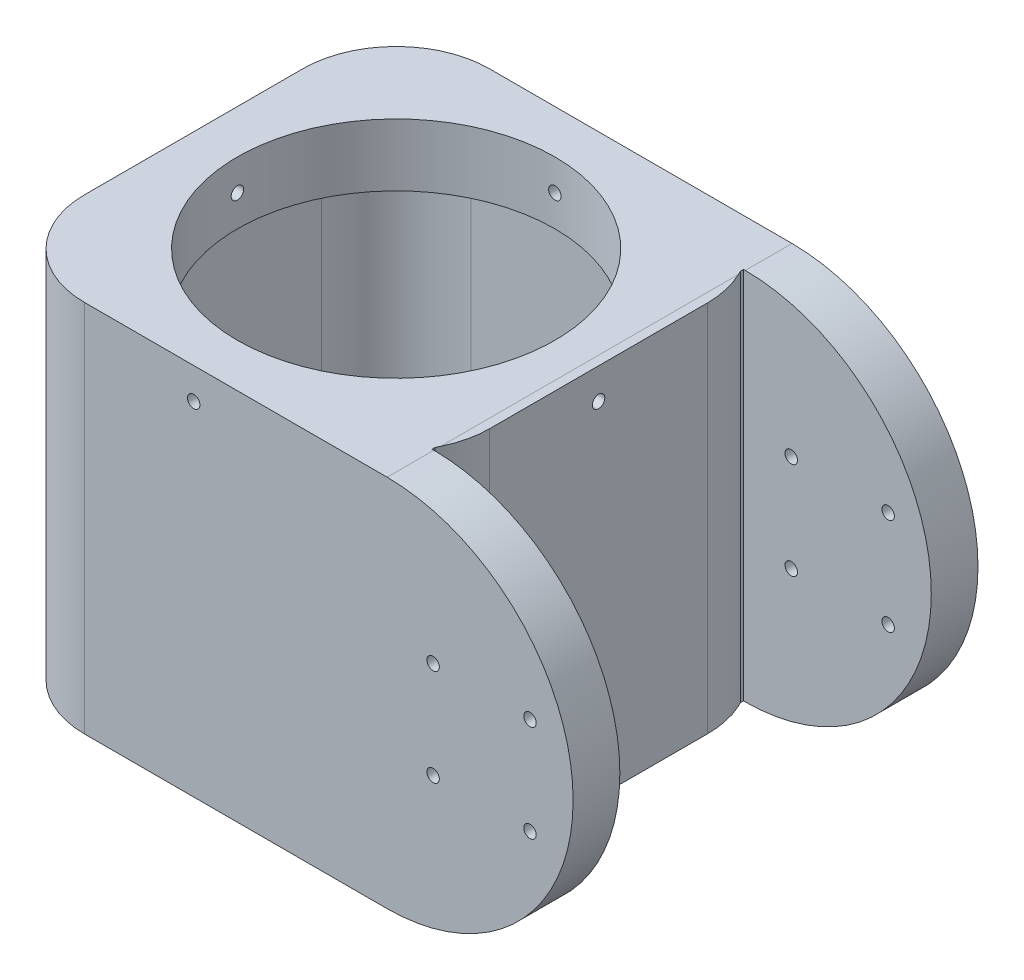
from build123d import *

# Parameters (mm, degrees)
BOSS_EXTRUDE1_DEPTH      = 40
SKETCH2_R                = 25.5
BOSS_EXTRUDE2_DEPTH      = 20
SKETCH3_R                = 4
CUT_EXTRUDE1_DEPTH       = 20
SKETCH5_R                = 1.5
CUT_EXTRUDE4_DEPTH       = 13.5
CUT_EXTRUDE5_DEPTH       = 3
BOSS_EXTRUDE3_DEPTH      = 60
CUT_EXTRUDE6_DEPTH       = 60
SKETCH9_R                = 1.5
CUT_EXTRUDE7_DEPTH       = 60
BOSS_EXTRUDE4_DEPTH      = 60
SKETCH12_R               = 1.5
CUT_EXTRUDE8_DEPTH       = 8
CUT_EXTRUDE9_DEPTH       = 0.5
CUT_EXTRUDE10_DEPTH      = 0.5
SKETCH15_R               = 4
SKETCH15_R_2             = 1.5
BOSS_EXTRUDE5_DEPTH      = 3
SKETCH16_R               = 1
CUT_EXTRUDE11_DEPTH      = 117
SKETCH19_R               = 1
BOSS_EXTRUDE7_DEPTH      = 43
SKETCH21_R               = 25.5
CUT_EXTRUDE12_DEPTH      = 33
CUT_EXTRUDE13_DEPTH      = 7
SKETCH24_R               = 1
CUT_EXTRUDE14_DEPTH      = 10
CUT_EXTRUDE14_DEPTH_BACK = 100
SKETCH25_R               = 1
CUT_EXTRUDE15_DEPTH      = 100
CUT_EXTRUDE15_DEPTH_BACK = 100
SKETCH29_R               = 1
BOSS_EXTRUDE9_DEPTH      = 10
SKETCH30_R               = 1.5
SKETCH30_R_2             = 1
BOSS_EXTRUDE10_DEPTH     = 7.5
SKETCH34_R               = 1.5
SKETCH34_R_2             = 1
BOSS_EXTRUDE12_DEPTH     = 7.5


with BuildPart() as part:
    # Sketch1 → Boss-Extrude1 (new body)
    with BuildSketch(Plane(origin=(0, 0, 0), x_dir=(1, 0, 0), z_dir=(0, 1, 0))):
        with BuildLine():
            Line((-17.090813971, 31.818023286), (17.909186029, 31.818023286))
            ThreePointArc((17.909186029, 31.818023286), (28.515787746, 27.424625004), (32.909186029, 16.818023286))
            Line((32.909186029, 16.818023286), (32.909186029, -18.181976714))
            ThreePointArc((32.909186029, -18.181976714), (28.515787746, -28.788578432), (17.909186029, -33.181976714))
            Line((17.909186029, -33.181976714), (-17.090813971, -33.181976714))
            ThreePointArc((-17.090813971, -33.181976714), (-27.697415689, -28.788578432), (-32.090813971, -18.181976714))
            Line((-32.090813971, -18.181976714), (-32.090813971, 16.818023286))
            ThreePointArc((-32.090813971, 16.818023286), (-27.697415689, 27.424625004), (-17.090813971, 31.818023286))
        make_face()
        with BuildLine():
            Line((-17.090813971, 28.818023286), (17.909186029, 28.818023286))
            ThreePointArc((17.909186029, 28.818023286), (26.394467403, 25.30330466), (29.909186029, 16.818023286))
            Line((29.909186029, 16.818023286), (29.909186029, -18.181976714))
            ThreePointArc((29.909186029, -18.181976714), (26.394467403, -26.667258088), (17.909186029, -30.181976714))
            Line((17.909186029, -30.181976714), (-17.090813971, -30.181976714))
            ThreePointArc((-17.090813971, -30.181976714), (-25.576095346, -26.667258088), (-29.090813971, -18.181976714))
            Line((-29.090813971, -18.181976714), (-29.090813971, 16.818023286))
            ThreePointArc((-29.090813971, 16.818023286), (-25.576095346, 25.30330466), (-17.090813971, 28.818023286))
        make_face(mode=Mode.SUBTRACT)
    extrude(amount=BOSS_EXTRUDE1_DEPTH)

    # Sketch2 → Boss-Extrude2 (add)
    with BuildSketch(Plane(origin=(0, 40, 0), x_dir=(1, 0, 0), z_dir=(0, 1, 0))):
        with BuildLine():
            ThreePointArc((32.909186029, 16.818023286), (28.515787746, 27.424625004), (17.909186029, 31.818023286))
            Line((17.909186029, 31.818023286), (-17.090813971, 31.818023286))
            ThreePointArc((-17.090813971, 31.818023286), (-27.697415689, 27.424625004), (-32.090813971, 16.818023286))
            Line((-32.090813971, 16.818023286), (-32.090813971, -18.181976714))
            ThreePointArc((-32.090813971, -18.181976714), (-27.697415689, -28.788578432), (-17.090813971, -33.181976714))
            Line((-17.090813971, -33.181976714), (17.909186029, -33.181976714))
            ThreePointArc((17.909186029, -33.181976714), (28.515787746, -28.788578432), (32.909186029, -18.181976714))
            Line((32.909186029, -18.181976714), (32.909186029, 16.818023286))
        make_face()
        with Locations((0.409186029, -0.681976714)):
            Circle(SKETCH2_R, mode=Mode.SUBTRACT)
    extrude(amount=BOSS_EXTRUDE2_DEPTH)

    # Sketch3 → Cut-Extrude1 (cut)
    with BuildSketch(Plane.XY.offset(33.181976714)):
        with Locations((0.409186029, 30)):
            Circle(SKETCH3_R)
    extrude(amount=-CUT_EXTRUDE1_DEPTH, mode=Mode.SUBTRACT)

    # Sketch5 → Cut-Extrude4 (cut)
    with BuildSketch(Plane.XY.offset(33.181976714)):
        with Locations((8.187360622, 22.221825407)):
            Circle(SKETCH5_R)
        with Locations((8.187360622, 37.778174593)):
            Circle(SKETCH5_R)
        with Locations((-7.368988565, 37.778174593)):
            Circle(SKETCH5_R)
        with Locations((-7.368988565, 22.221825407)):
            Circle(SKETCH5_R)
    extrude(amount=-CUT_EXTRUDE4_DEPTH, mode=Mode.SUBTRACT)

    # Sketch6 → Cut-Extrude5 (cut)
    with BuildSketch(Plane.XZ.offset(-40)):
        with BuildLine():
            Line((-17.090813971, -28.818023286), (17.909186029, -28.818023286))
            ThreePointArc((17.909186029, -28.818023286), (26.394467403, -25.30330466), (29.909186029, -16.818023286))
            Line((29.909186029, -16.818023286), (29.909186029, 18.181976714))
            ThreePointArc((29.909186029, 18.181976714), (26.394467403, 26.667258088), (17.909186029, 30.181976714))
            Line((17.909186029, 30.181976714), (-17.090813971, 30.181976714))
            ThreePointArc((-17.090813971, 30.181976714), (-25.576095346, 26.667258088), (-29.090813971, 18.181976714))
            Line((-29.090813971, 18.181976714), (-29.090813971, -16.818023286))
            ThreePointArc((-29.090813971, -16.818023286), (-25.576095346, -25.30330466), (-17.090813971, -28.818023286))
        make_face()
    extrude(amount=-CUT_EXTRUDE5_DEPTH, mode=Mode.SUBTRACT)

    # Sketch7 → Boss-Extrude3 (add)
    with BuildSketch(Plane.XZ):
        with BuildLine():
            Line((61.323991226, 25.181976714), (61.323991226, 33.181976714))
            Line((61.323991226, 33.181976714), (17.909186029, 33.181976714))
            ThreePointArc((17.909186029, 33.181976714), (25.655152721, 31.027209293), (31.17568519, 25.181976714))
            Line((31.17568519, 25.181976714), (61.323991226, 25.181976714))
        make_face()
    extrude(amount=-BOSS_EXTRUDE3_DEPTH)

    # Sketch8 → Cut-Extrude6 (cut)
    with BuildSketch(Plane.XY.offset(33.181976714)):
        with BuildLine():
            ThreePointArc((61.323991226, 30), (52.589328632, 8.838908407), (31.471567713, 0))
            Line((31.471567713, 0), (61.323991226, 0))
            Line((61.323991226, 0), (61.323991226, 30))
        make_face()
        with BuildLine():
            Line((61.323991226, 60), (31.471567713, 60))
            ThreePointArc((31.471567713, 60), (52.589328632, 51.161091593), (61.323991226, 30))
            Line((61.323991226, 30), (61.323991226, 60))
        make_face()
    extrude(amount=-CUT_EXTRUDE6_DEPTH, mode=Mode.SUBTRACT)

    # Sketch9 → Cut-Extrude7 (cut)
    with BuildSketch(Plane.XY.offset(33.181976714)):
        with Locations((54.39495386, 22.221825407)):
            Circle(SKETCH9_R)
        with Locations((38.838604674, 37.778174593)):
            Circle(SKETCH9_R)
        with Locations((54.39495386, 37.778174593)):
            Circle(SKETCH9_R)
        with Locations((38.838604674, 22.221825407)):
            Circle(SKETCH9_R)
    extrude(amount=-CUT_EXTRUDE7_DEPTH, mode=Mode.SUBTRACT)

    # Sketch11 → Boss-Extrude4 (add)
    with BuildSketch(Plane(origin=(0, 60, 0), x_dir=(1, 0, 0), z_dir=(0, 1, 0))):
        with BuildLine():
            Line((57.937839218, 31.818023286), (17.909186029, 31.818023286))
            ThreePointArc((17.909186029, 31.818023286), (25.655152721, 29.663255864), (31.17568519, 23.818023286))
            Line((31.17568519, 23.818023286), (58.682463464, 23.818023286))
            Line((58.682463464, 23.818023286), (61.323991226, 23.818023286))
            Line((61.323991226, 23.818023286), (61.323991226, 31.818023286))
            Line((61.323991226, 31.818023286), (57.937839218, 31.818023286))
        make_face()
    extrude(amount=-BOSS_EXTRUDE4_DEPTH)

    # Sketch12 → Cut-Extrude8 (cut)
    with BuildSketch(Plane(origin=(0, 0, -31.818023286), x_dir=(-1, 0, 0), z_dir=(0, 0, -1))):
        with BuildLine():
            Line((-61.323991226, 30), (-61.323991226, 0))
            Line((-61.323991226, 0), (-31.471567713, 0))
            ThreePointArc((-31.471567713, 0), (-52.589328632, 8.838908407), (-61.323991226, 30))
        make_face()
        with BuildLine():
            Line((-61.323991226, 60), (-61.323991226, 30))
            ThreePointArc((-61.323991226, 30), (-52.589328632, 51.161091593), (-31.471567713, 60))
            Line((-31.471567713, 60), (-61.323991226, 60))
        make_face()
        with Locations((-54.39495386, 37.778174593)):
            Circle(SKETCH12_R)
        with Locations((-54.39495386, 22.221825407)):
            Circle(SKETCH12_R)
        with Locations((-38.838604674, 22.221825407)):
            Circle(SKETCH12_R)
        with Locations((-38.838604674, 37.778174593)):
            Circle(SKETCH12_R)
    extrude(amount=-CUT_EXTRUDE8_DEPTH, mode=Mode.SUBTRACT)

    # Sketch13 → Cut-Extrude9 (cut)
    with BuildSketch(Plane(origin=(0, 0, 25.181976714), x_dir=(-1, 0, 0), z_dir=(0, 0, -1))):
        with BuildLine():
            Line((-31.17568519, 60), (-31.471567713, 60))
            ThreePointArc((-31.471567713, 60), (-61.323991226, 30), (-31.471567713, 0))
            Line((-31.471567713, 0), (-31.17568519, 0))
            Line((-31.17568519, 0), (-31.17568519, 60))
        make_face()
    extrude(amount=-CUT_EXTRUDE9_DEPTH, mode=Mode.SUBTRACT)

    # Sketch14 → Cut-Extrude10 (cut)
    with BuildSketch(Plane.XY.offset(-23.818023286)):
        with BuildLine():
            Line((31.17568519, 0), (31.471567713, 0))
            ThreePointArc((31.471567713, 0), (61.323991226, 30), (31.471567713, 60))
            Line((31.471567713, 60), (31.17568519, 60))
            Line((31.17568519, 60), (31.17568519, 0))
        make_face()
    extrude(amount=-CUT_EXTRUDE10_DEPTH, mode=Mode.SUBTRACT)

    # Sketch15 → Boss-Extrude5 (add)
    with BuildSketch(Plane.XY.offset(33.181976714)):
        with Locations((0.409186029, 30)):
            Circle(SKETCH15_R)
        with Locations((-7.368988565, 22.221825407)):
            Circle(SKETCH15_R_2)
        with Locations((8.187360622, 22.221825407)):
            Circle(SKETCH15_R_2)
        with Locations((8.187360622, 37.778174593)):
            Circle(SKETCH15_R_2)
        with Locations((-7.368988565, 37.778174593)):
            Circle(SKETCH15_R_2)
    extrude(amount=-BOSS_EXTRUDE5_DEPTH)

    # Sketch16 → Cut-Extrude11 (cut)
    with BuildSketch(Plane.XZ.offset(-43)):
        with Locations((22.151826716, 22.650712067)):
            Circle(SKETCH16_R)
        with Locations((-21.559549324, 22.424617401)):
            Circle(SKETCH16_R)
        with Locations((-21.333454659, -21.286758638)):
            Circle(SKETCH16_R)
        with Locations((22.377921381, -21.060663973)):
            Circle(SKETCH16_R)
    extrude(amount=-CUT_EXTRUDE11_DEPTH, mode=Mode.SUBTRACT)

    # Sketch19 → Boss-Extrude7 (add)
    with BuildSketch(Plane.XZ.offset(-43)):
        with BuildLine():
            ThreePointArc((17.909186029, 30.181976714), (19.971047838, 20.243838524), (29.909186029, 18.181976714))
            ThreePointArc((29.909186029, 18.181976714), (26.394467403, 26.667258088), (17.909186029, 30.181976714))
        make_face()
        with Locations((22.151826716, 22.650712067)):
            Circle(SKETCH19_R, mode=Mode.SUBTRACT)
        with BuildLine():
            ThreePointArc((29.909186029, -16.818023286), (19.971047838, -18.879885095), (17.909186029, -28.818023286))
            ThreePointArc((17.909186029, -28.818023286), (26.394467403, -25.30330466), (29.909186029, -16.818023286))
        make_face()
        with Locations((22.377921381, -21.060663973)):
            Circle(SKETCH19_R, mode=Mode.SUBTRACT)
        with BuildLine():
            ThreePointArc((-17.090813971, -28.818023286), (-19.152675781, -18.879885095), (-29.090813971, -16.818023286))
            ThreePointArc((-29.090813971, -16.818023286), (-25.576095346, -25.30330466), (-17.090813971, -28.818023286))
        make_face()
        with Locations((-21.333454659, -21.286758638)):
            Circle(SKETCH19_R, mode=Mode.SUBTRACT)
        with BuildLine():
            ThreePointArc((-29.090813971, 18.181976714), (-19.152675781, 20.243838524), (-17.090813971, 30.181976714))
            ThreePointArc((-17.090813971, 30.181976714), (-25.576095346, 26.667258088), (-29.090813971, 18.181976714))
        make_face()
        with Locations((-21.559549324, 22.424617401)):
            Circle(SKETCH19_R, mode=Mode.SUBTRACT)
    extrude(amount=BOSS_EXTRUDE7_DEPTH)

    # Sketch21 → Cut-Extrude12 (cut)
    with BuildSketch(Plane(origin=(0, 10, 0), x_dir=(-1, 0, 0), z_dir=(0, -1, 0))):
        with Locations((-0.409186029, -0.681976714)):
            Circle(SKETCH21_R)
        with BuildLine():
            ThreePointArc((-29.909186029, 16.818023286), (-26.394467403, 25.30330466), (-17.909186029, 28.818023286))
            ThreePointArc((-17.909186029, 28.818023286), (-19.971047838, 18.879885095), (-29.909186029, 16.818023286))
        make_face()
        with BuildLine():
            ThreePointArc((17.090813971, 28.818023286), (19.152675781, 18.879885095), (29.090813971, 16.818023286))
            ThreePointArc((29.090813971, 16.818023286), (25.576095346, 25.30330466), (17.090813971, 28.818023286))
        make_face()
        with BuildLine():
            ThreePointArc((29.090813971, -18.181976714), (19.152675781, -20.243838524), (17.090813971, -30.181976714))
            ThreePointArc((17.090813971, -30.181976714), (25.576095346, -26.667258088), (29.090813971, -18.181976714))
        make_face()
        with BuildLine():
            ThreePointArc((-17.909186029, -30.181976714), (-19.971047838, -20.243838524), (-29.909186029, -18.181976714))
            ThreePointArc((-29.909186029, -18.181976714), (-26.394467403, -26.667258088), (-17.909186029, -30.181976714))
        make_face()
    extrude(amount=-CUT_EXTRUDE12_DEPTH, mode=Mode.SUBTRACT)

    # Sketch23 → Cut-Extrude13 (cut)
    with BuildSketch(Plane.XZ.offset(-43)):
        with BuildLine():
            Line((17.909186029, 30.181976714), (-17.090813971, 30.181976714))
            ThreePointArc((-17.090813971, 30.181976714), (-25.576095346, 26.667258088), (-29.090813971, 18.181976714))
            Line((-29.090813971, 18.181976714), (-29.090813971, -16.818023286))
            ThreePointArc((-29.090813971, -16.818023286), (-25.576095346, -25.30330466), (-17.090813971, -28.818023286))
            Line((-17.090813971, -28.818023286), (17.909186029, -28.818023286))
            ThreePointArc((17.909186029, -28.818023286), (26.394467403, -25.30330466), (29.909186029, -16.818023286))
            Line((29.909186029, -16.818023286), (29.909186029, 18.181976714))
            ThreePointArc((29.909186029, 18.181976714), (26.394467403, 26.667258088), (17.909186029, 30.181976714))
        make_face()
    extrude(amount=-CUT_EXTRUDE13_DEPTH, mode=Mode.SUBTRACT)

    # Sketch24 → Cut-Extrude14 (cut, two sides)
    with BuildSketch(Plane.XY.offset(33.181976714)) as cut_extrude14_sk:
        with Locations((0.409186029, 55)):
            Circle(SKETCH24_R)
    extrude(amount=CUT_EXTRUDE14_DEPTH, mode=Mode.SUBTRACT)
    extrude(cut_extrude14_sk.sketch, amount=-CUT_EXTRUDE14_DEPTH_BACK, mode=Mode.SUBTRACT)

    # Sketch25 → Cut-Extrude15 (cut, two sides)
    with BuildSketch(Plane(origin=(32.909186029, 0, 0), x_dir=(0, 0, -1), z_dir=(1, 0, 0))) as cut_extrude15_sk:
        with Locations((-0.681976714, 55)):
            Circle(SKETCH25_R)
    extrude(amount=CUT_EXTRUDE15_DEPTH, mode=Mode.SUBTRACT)
    extrude(cut_extrude15_sk.sketch, amount=-CUT_EXTRUDE15_DEPTH_BACK, mode=Mode.SUBTRACT)

    # Sketch29 → Boss-Extrude9 (add)
    with BuildSketch(Plane.XZ.offset(-50)):
        with Locations((22.151826716, 22.650712067)):
            Circle(SKETCH29_R)
        with Locations((-21.559549324, 22.424617401)):
            Circle(SKETCH29_R)
        with Locations((-21.333454659, -21.286758638)):
            Circle(SKETCH29_R)
        with Locations((22.377921381, -21.060663973)):
            Circle(SKETCH29_R)
    extrude(amount=-BOSS_EXTRUDE9_DEPTH)

    # Sketch30 → Boss-Extrude10 (add)
    with BuildSketch(Plane(origin=(0, 0, -31.818023286), x_dir=(-1, 0, 0), z_dir=(0, 0, -1))):
        with Locations((-54.39495386, 22.221825407)):
            Circle(SKETCH30_R)
        with Locations((-54.39495386, 22.221825407)):
            Circle(SKETCH30_R_2, mode=Mode.SUBTRACT)
        with Locations((-38.838604674, 37.778174593)):
            Circle(SKETCH30_R)
        with Locations((-38.838604674, 37.778174593)):
            Circle(SKETCH30_R_2, mode=Mode.SUBTRACT)
        with Locations((-54.39495386, 37.778174593)):
            Circle(SKETCH30_R)
        with Locations((-54.39495386, 37.778174593)):
            Circle(SKETCH30_R_2, mode=Mode.SUBTRACT)
        with Locations((-38.838604674, 22.221825407)):
            Circle(SKETCH30_R)
        with Locations((-38.838604674, 22.221825407)):
            Circle(SKETCH30_R_2, mode=Mode.SUBTRACT)
    extrude(amount=-BOSS_EXTRUDE10_DEPTH)

    # Sketch34 → Boss-Extrude12 (add)
    with BuildSketch(Plane.XY.offset(33.181976714)):
        with Locations((54.39495386, 22.221825407)):
            Circle(SKETCH34_R)
        with Locations((54.39495386, 22.221825407)):
            Circle(SKETCH34_R_2, mode=Mode.SUBTRACT)
        with Locations((38.838604674, 22.221825407)):
            Circle(SKETCH34_R)
        with Locations((38.838604674, 22.221825407)):
            Circle(SKETCH34_R_2, mode=Mode.SUBTRACT)
        with Locations((38.838604674, 37.778174593)):
            Circle(SKETCH34_R)
        with Locations((38.838604674, 37.778174593)):
            Circle(SKETCH34_R_2, mode=Mode.SUBTRACT)
        with Locations((54.39495386, 37.778174593)):
            Circle(SKETCH34_R)
        with Locations((54.39495386, 37.778174593)):
            Circle(SKETCH34_R_2, mode=Mode.SUBTRACT)
    extrude(amount=-BOSS_EXTRUDE12_DEPTH)


solid = part.part
